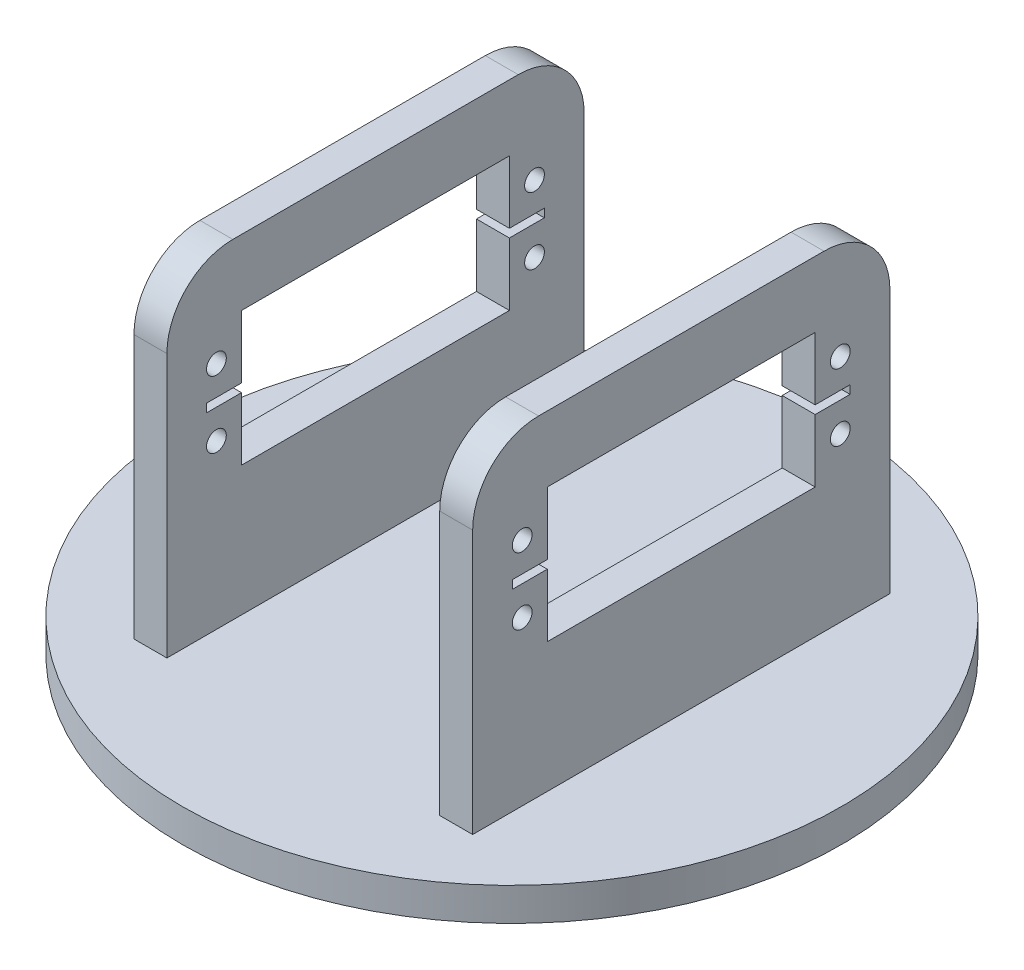
from build123d import *

# Parameters (mm, degrees)
SKETCH1_R                = 50
SKETCH1_R_2              = 2.778
BOSS_EXTRUDE1_DEPTH      = 2.5
SKETCH2_W                = 5
SKETCH2_H                = 63.3
BOSS_EXTRUDE2_DEPTH      = 50
FILLET1_R                = 10
SKETCH14_W               = 40.64
SKETCH14_H               = 20.32
CUT_EXTRUDE1_DEPTH       = 30.305745908
F_3_0_3_DIAMETER_HOLE1_D = 3
FILLET1_OF_MIRROR1_R     = 10


with BuildPart() as part:
    # Sketch1 → Boss-Extrude1 (new body, symmetric)
    with BuildSketch(Plane(origin=(0, 0, 0), x_dir=(1, 0, 0), z_dir=(0, 1, 0))):
        Circle(SKETCH1_R)
        Circle(SKETCH1_R_2, mode=Mode.SUBTRACT)
    extrude(amount=BOSS_EXTRUDE1_DEPTH, both=True)

    # Sketch2 → Boss-Extrude2 (add)
    with BuildSketch(Plane(origin=(0, 2.5, 0), x_dir=(1, 0, 0), z_dir=(0, 1, 0))):
        with Locations((-23.194254092, 0)):
            Rectangle(SKETCH2_W, SKETCH2_H)
    boss_extrude2 = extrude(amount=BOSS_EXTRUDE2_DEPTH)

    # Fillet1
    fillet1_edges = [part.edges().sort_by_distance(p)[0] for p in [
        (-23.194254092, 52.5, -31.65),
        (-23.194254092, 52.5, 31.65),
    ]]
    fillet(fillet1_edges, radius=FILLET1_R)

    # Sketch14 → Cut-Extrude1 (cut, through all)
    with BuildSketch(Plane(origin=(-20.694254092, 0, 0), x_dir=(0, 0, -1), z_dir=(1, 0, 0))):
        with Locations((-0.01, 32.34)):
            Rectangle(SKETCH14_W, SKETCH14_H)
        Polygon((-20.33, 31.705), (-20.33, 32.975), (-25.63, 32.975), (-25.63, 32.34), (-25.63, 31.705), align=None)
        Polygon((25.61, 32.975), (20.31, 32.975), (20.31, 31.705), (25.61, 31.705), (25.61, 32.34), align=None)
    cut_extrude1 = extrude(amount=-CUT_EXTRUDE1_DEPTH, mode=Mode.SUBTRACT)

    # Ø3.0 (3) Diameter Hole1 (through all)
    with Locations(Plane(origin=(-20.694254092, 0, 0), x_dir=(0, 0, -1), z_dir=(1, 0, 0))):
        with Locations((24.12, 37.42), (24.12, 27.26), (-24.14, 37.42), (-24.14, 27.26)):
            f_3_0_3_diameter_hole1 = Hole(F_3_0_3_DIAMETER_HOLE1_D / 2)

    # Mirror1: Boss-Extrude2, Cut-Extrude1, Ø3.0 (3) Diameter Hole1 across plane
    add(boss_extrude2.mirror(Plane(origin=(0, 0, 0), x_dir=(0, 0, 1), z_dir=(1, 0, 0))))
    add(cut_extrude1.mirror(Plane(origin=(0, 0, 0), x_dir=(0, 0, 1), z_dir=(1, 0, 0))), mode=Mode.SUBTRACT)
    add(f_3_0_3_diameter_hole1.mirror(Plane(origin=(0, 0, 0), x_dir=(0, 0, 1), z_dir=(1, 0, 0))), mode=Mode.SUBTRACT)

    # Fillet1 of Mirror1
    fillet1_of_mirror1_edges = [part.edges().sort_by_distance(p)[0] for p in [
        (23.194254092, 52.5, -31.65),
        (23.194254092, 52.5, 31.65),
    ]]
    fillet(fillet1_of_mirror1_edges, radius=FILLET1_OF_MIRROR1_R)


solid = part.part
